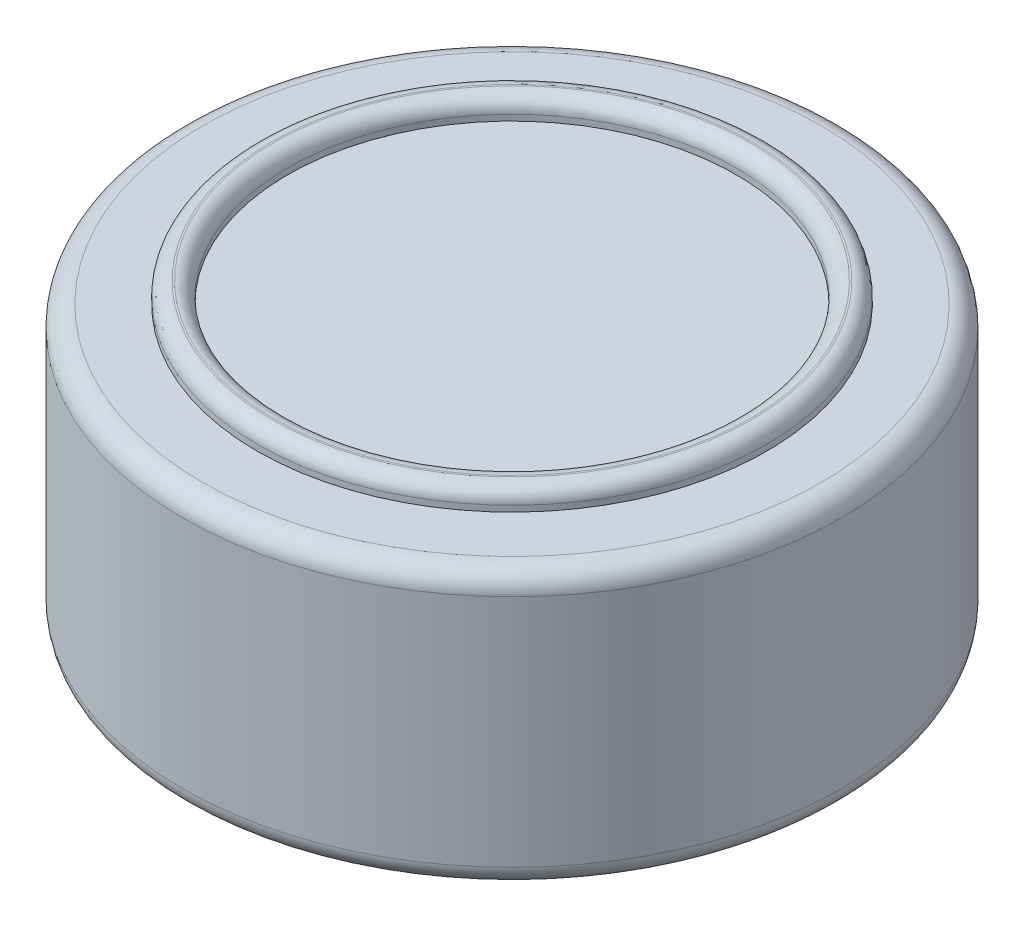
from build123d import *

# Parameters (mm, degrees)
SKETCH1_R           = 16.1655
BOSS_EXTRUDE1_DEPTH = 13.5
FILLET1_R           = 1
SKETCH2_R           = 12.5
SKETCH2_R_2         = 11
BOSS_EXTRUDE2_DEPTH = 1
FILLET4_R           = 0.707


with BuildPart() as part:
    # Sketch1 → Boss-Extrude1 (new body)
    with BuildSketch(Plane(origin=(0, 0, 0), x_dir=(1, 0, 0), z_dir=(0, 1, 0))):
        Circle(SKETCH1_R)
    extrude(amount=BOSS_EXTRUDE1_DEPTH)

    # Fillet1
    fillet1_edges = [part.edges().sort_by_distance(p)[0] for p in [
        (-16.1655, 0, 0),
        (-16.1655, 13.5, 0),
    ]]
    fillet(fillet1_edges, radius=FILLET1_R)

    # Sketch2 → Boss-Extrude2 (add)
    with BuildSketch(Plane(origin=(0, 13.5, 0), x_dir=(1, 0, 0), z_dir=(0, 1, 0))):
        Circle(SKETCH2_R)
        Circle(SKETCH2_R_2, mode=Mode.SUBTRACT)
    extrude(amount=BOSS_EXTRUDE2_DEPTH)

    # Fillet4
    fillet4_edges = [part.edges().sort_by_distance(p)[0] for p in [
        (-12.5, 14.5, 0),
        (-11, 14.5, 0),
    ]]
    fillet(fillet4_edges, radius=FILLET4_R)


solid = part.part
